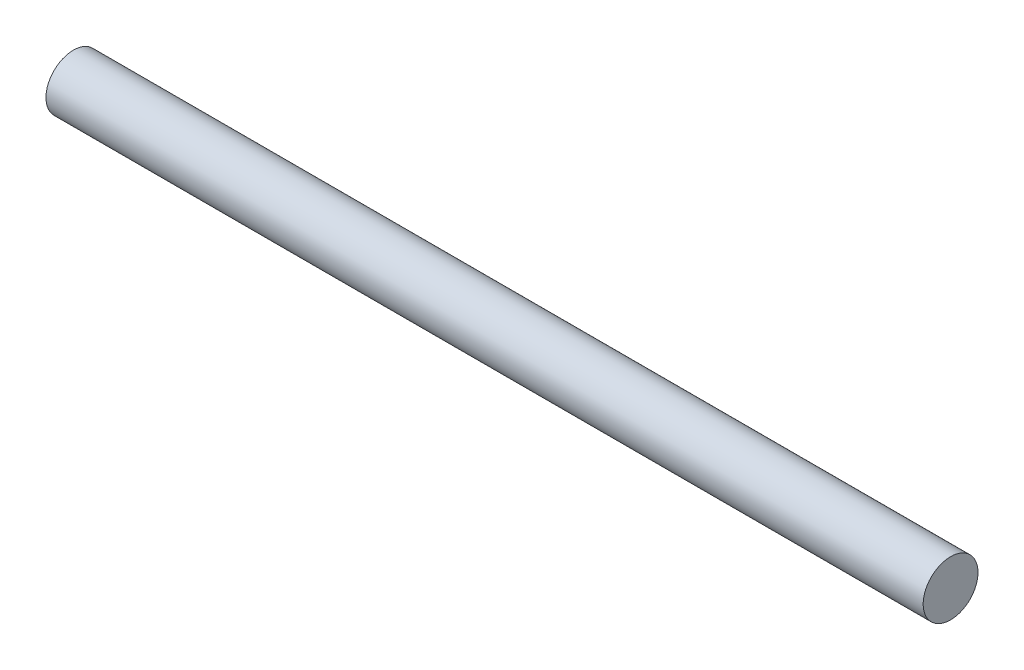
from build123d import *

# Parameters (mm, degrees)
SKETCH1_R           = 0.25
BOSS_EXTRUDE1_DEPTH = 8


with BuildPart() as part:
    # Sketch1 → Boss-Extrude1 (new body)
    with BuildSketch(Plane(origin=(0, 0, 0), x_dir=(0, 0, -1), z_dir=(1, 0, 0))):
        Circle(SKETCH1_R)
    extrude(amount=BOSS_EXTRUDE1_DEPTH)


solid = part.part
